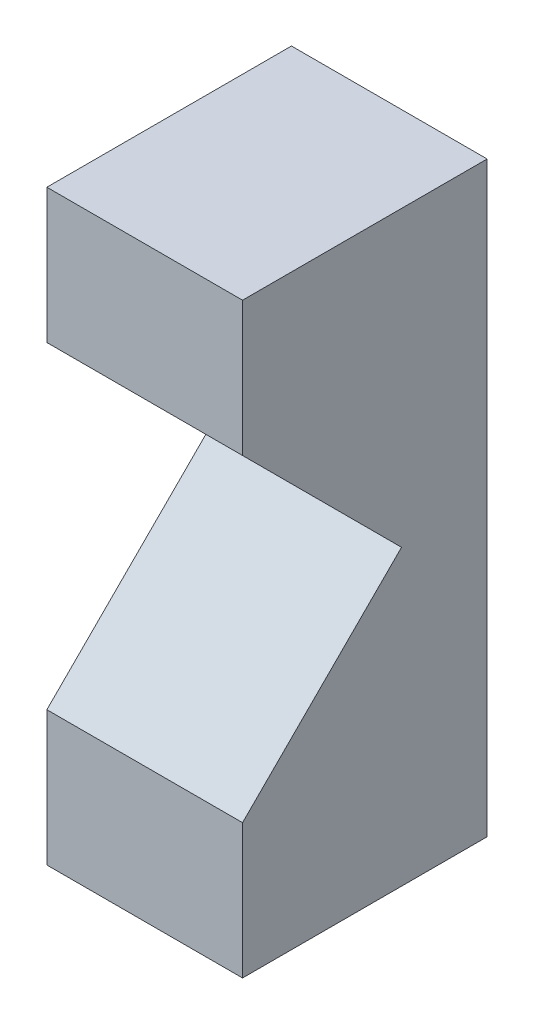
from build123d import *

# Parameters (mm, degrees)
BOSS_EXTRUDE1_DEPTH = 12.7


with BuildPart() as part:
    # Sketch1 → Boss-Extrude1 (new body)
    with BuildSketch(Plane(origin=(0, 0, 0), x_dir=(0, 0, -1), z_dir=(1, 0, 0))):
        Polygon((0, 10.31875), (10.31875, 0), (0, -10.31875), (0, -19.05), (15.875, -19.05), (15.875, 19.05), (0, 19.05), align=None)
    extrude(amount=BOSS_EXTRUDE1_DEPTH)


solid = part.part
